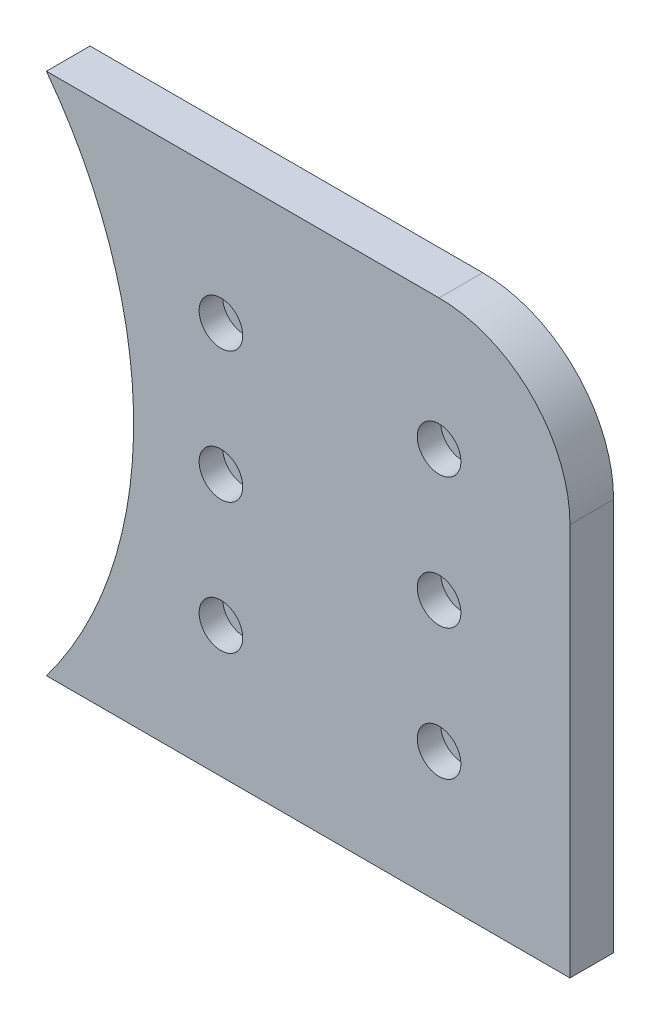
from build123d import *

# Parameters (mm, degrees)
AUFSATZ_LINEAR_AUSTRAGEN1_DEPTH                      = 5
VERRUNDUNG1_R                                        = 30
STIRNSENKUNG_F_R_M5_ZYLINDERSCHRAUBE_MIT_D           = 5.3
STIRNSENKUNG_F_R_M5_ZYLINDERSCHRAUBE_MIT_CBORE_D     = 10
STIRNSENKUNG_F_R_M5_ZYLINDERSCHRAUBE_MIT_CBORE_DEPTH = 5.4
LINEARES_MUSTER1_COUNT                               = 3
LINEARES_MUSTER1_PITCH                               = 30
LINEARES_MUSTER1_COUNT_DIR2                          = 2
LINEARES_MUSTER1_PITCH_DIR2                          = 50


with BuildPart() as part:
    # Skizze1 → Aufsatz-Linear austragen1 (new body, symmetric)
    with BuildSketch(Plane.XY):
        with BuildLine():
            Line((-120, 60), (0, 60))
            Line((0, 60), (0, -60))
            Line((0, -60), (-120, -60))
            ThreePointArc((-120, -60), (-100, 0), (-120, 60))
        make_face()
    extrude(amount=AUFSATZ_LINEAR_AUSTRAGEN1_DEPTH, both=True)

    # Verrundung1
    verrundung1_edges = [part.edges().sort_by_distance(p)[0] for p in [
        (0, 60, 0),
    ]]
    fillet(verrundung1_edges, radius=VERRUNDUNG1_R)

    # Stirnsenkung für M5 Zylinderschraube mit Innensechskant1 (through all)
    with Locations(Plane.XY.offset(5)):
        with Locations((-30, 30)):
            stirnsenkung_f_r_m5_zylinderschraube_mit = CounterBoreHole(STIRNSENKUNG_F_R_M5_ZYLINDERSCHRAUBE_MIT_D / 2, STIRNSENKUNG_F_R_M5_ZYLINDERSCHRAUBE_MIT_CBORE_D / 2, STIRNSENKUNG_F_R_M5_ZYLINDERSCHRAUBE_MIT_CBORE_DEPTH)

    # Lineares Muster1: Stirnsenkung f_r M5 Zylinderschraube mit 3 × 2
    with Locations(*[(-j * LINEARES_MUSTER1_PITCH_DIR2, -i * LINEARES_MUSTER1_PITCH, 0) for i in range(LINEARES_MUSTER1_COUNT) for j in range(LINEARES_MUSTER1_COUNT_DIR2) if (i, j) != (0, 0)]):
        add(stirnsenkung_f_r_m5_zylinderschraube_mit, mode=Mode.SUBTRACT)


solid = part.part
